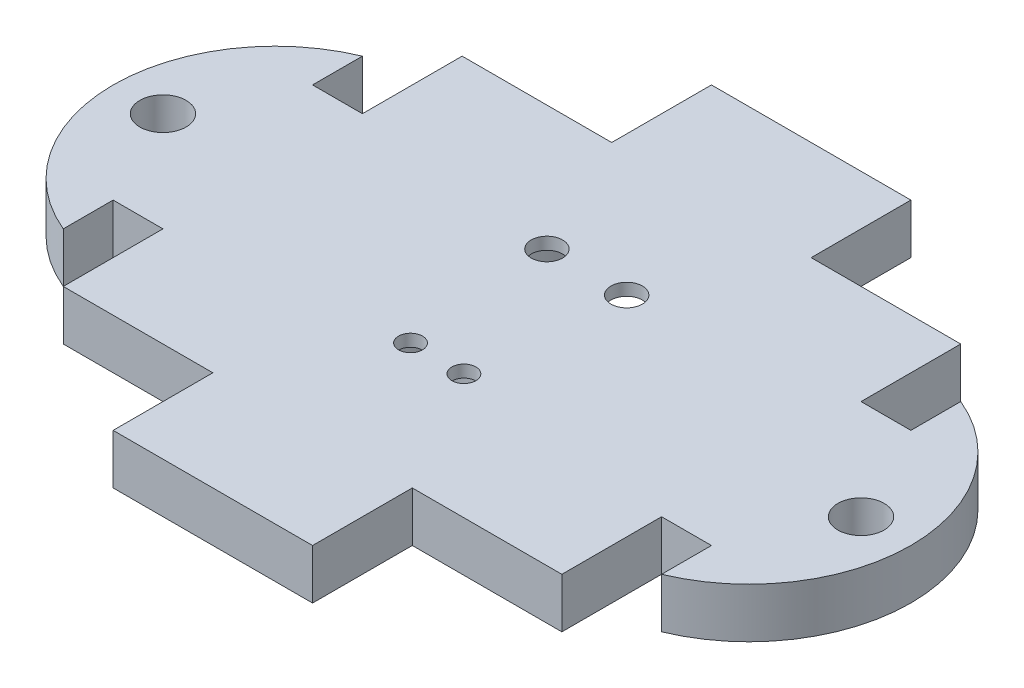
from build123d import *

# Parameters (mm, degrees)
BOSS_EXTRUDE1_DEPTH       = 3.175
F_4_CLEARANCE_HOLE1_D     = 2.9464
F_4_CLEARANCE_HOLE1_DEPTH = 6.35
F_4_CLEARANCE_HOLE1_TIP   = 0.885187864
CUT_EXTRUDE3_REACH        = 33.908
SKETCH4_R                 = 0.762
SKETCH4_R_2               = 1
SKETCH4_3_R               = 5.08
SKETCH4_3_R_2             = 1
SKETCH4_3_R_3             = 2.6035
SKETCH4_3_R_4             = 0.762
CUT_EXTRUDE4_DEPTH        = 2.4


with BuildPart() as part:
    # Sketch1 → Boss-Extrude1 (new body)
    with BuildSketch(Plane(origin=(0, 0, 0), x_dir=(1, 0, 0), z_dir=(0, 1, 0))):
        with BuildLine():
            Line((-15.875, 12.7), (-6.35, 12.7))
            Line((-6.35, 12.7), (-6.35, 19.05))
            Line((-6.35, 19.05), (6.35, 19.05))
            Line((6.35, 19.05), (6.35, 12.7))
            Line((6.35, 12.7), (15.875, 12.7))
            Line((15.875, 12.7), (15.875, 6.35))
            Line((15.875, 6.35), (19.05, 6.35))
            Line((19.05, 6.35), (19.05, 9.525))
            ThreePointArc((19.05, 9.525), (25.4, 0), (19.05, -9.525))
            Line((19.05, -9.525), (19.05, -6.35))
            Line((19.05, -6.35), (15.875, -6.35))
            Line((15.875, -6.35), (15.875, -12.7))
            Line((15.875, -12.7), (6.35, -12.7))
            Line((6.35, -12.7), (6.35, -19.05))
            Line((6.35, -19.05), (-6.35, -19.05))
            Line((-6.35, -19.05), (-6.35, -12.7))
            Line((-6.35, -12.7), (-15.875, -12.7))
            Line((-15.875, -12.7), (-15.875, -6.35))
            Line((-15.875, -6.35), (-19.05, -6.35))
            Line((-19.05, -6.35), (-19.05, -9.525))
            ThreePointArc((-19.05, -9.525), (-25.4, 0), (-19.05, 9.525))
            Line((-19.05, 9.525), (-19.05, 6.35))
            Line((-19.05, 6.35), (-15.875, 6.35))
            Line((-15.875, 6.35), (-15.875, 12.7))
        make_face()
    extrude(amount=BOSS_EXTRUDE1_DEPTH)

    # 4 Clearance Hole1
    with Locations(Plane(origin=(0, 3.175, 0), x_dir=(-1, 0, 0), z_dir=(0, 1, 0))):
        with Locations((-22.225, 0), (22.225, 0)):
            Hole(F_4_CLEARANCE_HOLE1_D / 2, depth=F_4_CLEARANCE_HOLE1_DEPTH)
            with Locations((0, 0, -(F_4_CLEARANCE_HOLE1_DEPTH + F_4_CLEARANCE_HOLE1_TIP / 2))):  # 118° drill point
                Cone(0, F_4_CLEARANCE_HOLE1_D / 2, F_4_CLEARANCE_HOLE1_TIP, mode=Mode.SUBTRACT)

    # Sketch4 → Cut-Extrude3 (cut, up to next)
    with BuildSketch(Plane(origin=(0, 0, 0), x_dir=(1, 0, 0), z_dir=(0, 1, 0)), mode=Mode.PRIVATE) as cut_extrude3_sk1:
        with Locations((-1.7, -4.7625)):
            Circle(SKETCH4_R)
    cut_extrude3_tool1 = extrude(cut_extrude3_sk1.sketch, amount=CUT_EXTRUDE3_REACH, mode=Mode.PRIVATE) & part.part
    # Sketch4 → Cut-Extrude3 (cut, up to next)
    with BuildSketch(Plane(origin=(0, 0, 0), x_dir=(1, 0, 0), z_dir=(0, 1, 0)), mode=Mode.PRIVATE) as cut_extrude3_sk2:
        with Locations((1.7, -4.7625)):
            Circle(SKETCH4_R)
    cut_extrude3_tool2 = extrude(cut_extrude3_sk2.sketch, amount=CUT_EXTRUDE3_REACH, mode=Mode.PRIVATE) & part.part
    # Sketch4 → Cut-Extrude3 (cut, up to next)
    with BuildSketch(Plane(origin=(0, 0, 0), x_dir=(1, 0, 0), z_dir=(0, 1, 0)), mode=Mode.PRIVATE) as cut_extrude3_sk3:
        with Locations((-2.54, 4.7625)):
            Circle(SKETCH4_R_2)
    cut_extrude3_tool3 = extrude(cut_extrude3_sk3.sketch, amount=CUT_EXTRUDE3_REACH, mode=Mode.PRIVATE) & part.part
    # Sketch4 → Cut-Extrude3 (cut, up to next)
    with BuildSketch(Plane(origin=(0, 0, 0), x_dir=(1, 0, 0), z_dir=(0, 1, 0)), mode=Mode.PRIVATE) as cut_extrude3_sk4:
        with Locations((2.54, 4.7625)):
            Circle(SKETCH4_R_2)
    cut_extrude3_tool4 = extrude(cut_extrude3_sk4.sketch, amount=CUT_EXTRUDE3_REACH, mode=Mode.PRIVATE) & part.part
    add(cut_extrude3_tool1.solids().sort_by_distance((-1.7, 0, 4.7625))[0], mode=Mode.SUBTRACT)
    add(cut_extrude3_tool2.solids().sort_by_distance((1.7, 0, 4.7625))[0], mode=Mode.SUBTRACT)
    add(cut_extrude3_tool3.solids().sort_by_distance((-2.54, 0, -4.7625))[0], mode=Mode.SUBTRACT)
    add(cut_extrude3_tool4.solids().sort_by_distance((2.54, 0, -4.7625))[0], mode=Mode.SUBTRACT)

    # Sketch4_3 → Cut-Extrude4 (cut)
    # profile 1 of 2: a face of its own
    with BuildSketch(Plane(origin=(0, 0, 0), x_dir=(1, 0, 0), z_dir=(0, 1, 0))):
        with Locations((0, 4.7625)):
            Circle(SKETCH4_3_R)
        with Locations((-2.54, 4.7625)):
            Circle(SKETCH4_3_R_2, mode=Mode.SUBTRACT)
        with Locations((2.54, 4.7625)):
            Circle(SKETCH4_3_R_2, mode=Mode.SUBTRACT)
    # profile 2 of 2: a face of its own
    with BuildSketch(Plane(origin=(0, 0, 0), x_dir=(1, 0, 0), z_dir=(0, 1, 0))):
        with Locations((0, -4.7625)):
            Circle(SKETCH4_3_R_3)
        with Locations((-1.7, -4.7625)):
            Circle(SKETCH4_3_R_4, mode=Mode.SUBTRACT)
    extrude(amount=CUT_EXTRUDE4_DEPTH, mode=Mode.SUBTRACT)


solid = part.part
